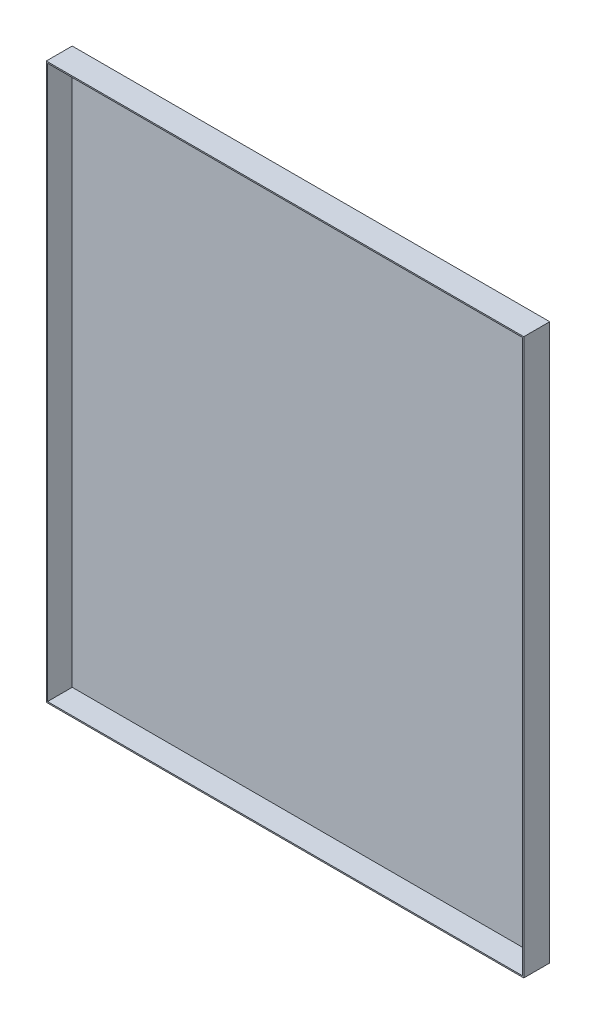
from build123d import *

# Parameters (mm, degrees)
SKETCH_1_W      = 368
SKETCH_1_H      = 428
EXTRUDE_1_DEPTH = 20
SHELL_1_T       = -1


with BuildPart() as part:
    # 草图1 → 凸台-拉伸1 (new body)
    with BuildSketch(Plane.XY):
        Rectangle(SKETCH_1_W, SKETCH_1_H)
    extrude(amount=EXTRUDE_1_DEPTH)

    # 抽壳1
    shell_1_openings = [part.faces().sort_by_distance(p)[0] for p in [
        (0, 0, 20),
    ]]
    offset(amount=SHELL_1_T, openings=shell_1_openings, kind=Kind.INTERSECTION)


solid = part.part
